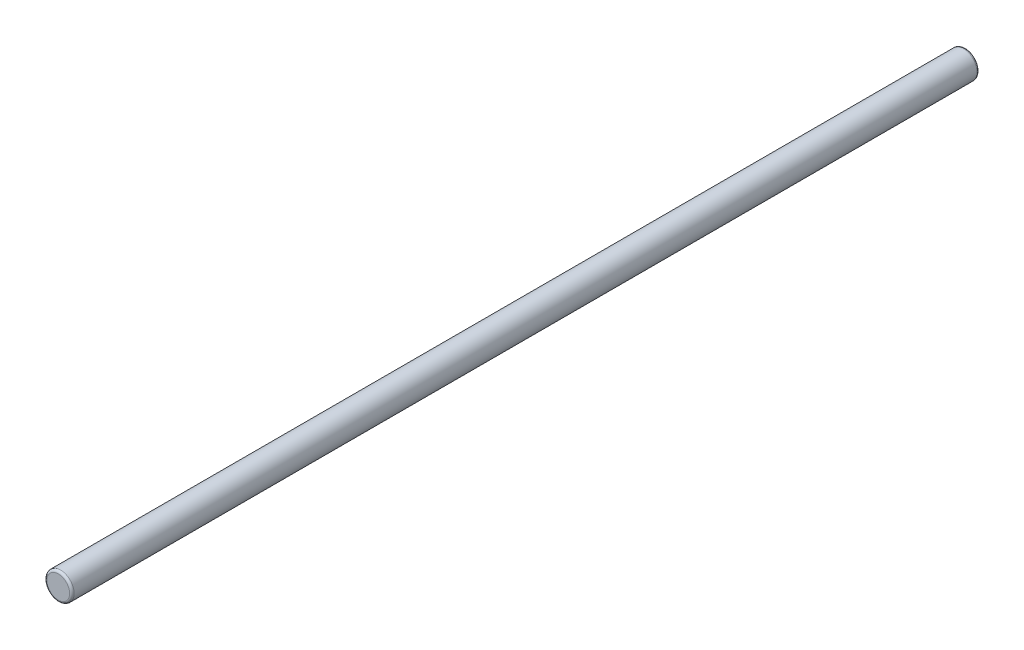
from build123d import *

# Parameters (mm, degrees)
SKETCH1_R           = 1.5
BOSS_EXTRUDE1_DEPTH = 100
FILLET1_R           = 0.25


with BuildPart() as part:
    # Sketch1 → Boss-Extrude1 (new body)
    with BuildSketch(Plane.XY):
        Circle(SKETCH1_R)
    extrude(amount=BOSS_EXTRUDE1_DEPTH)

    # Fillet1
    fillet1_edges = [part.edges().sort_by_distance(p)[0] for p in [
        (-1.5, 0, 0),
        (-1.5, 0, 100),
    ]]
    fillet(fillet1_edges, radius=FILLET1_R)


solid = part.part
